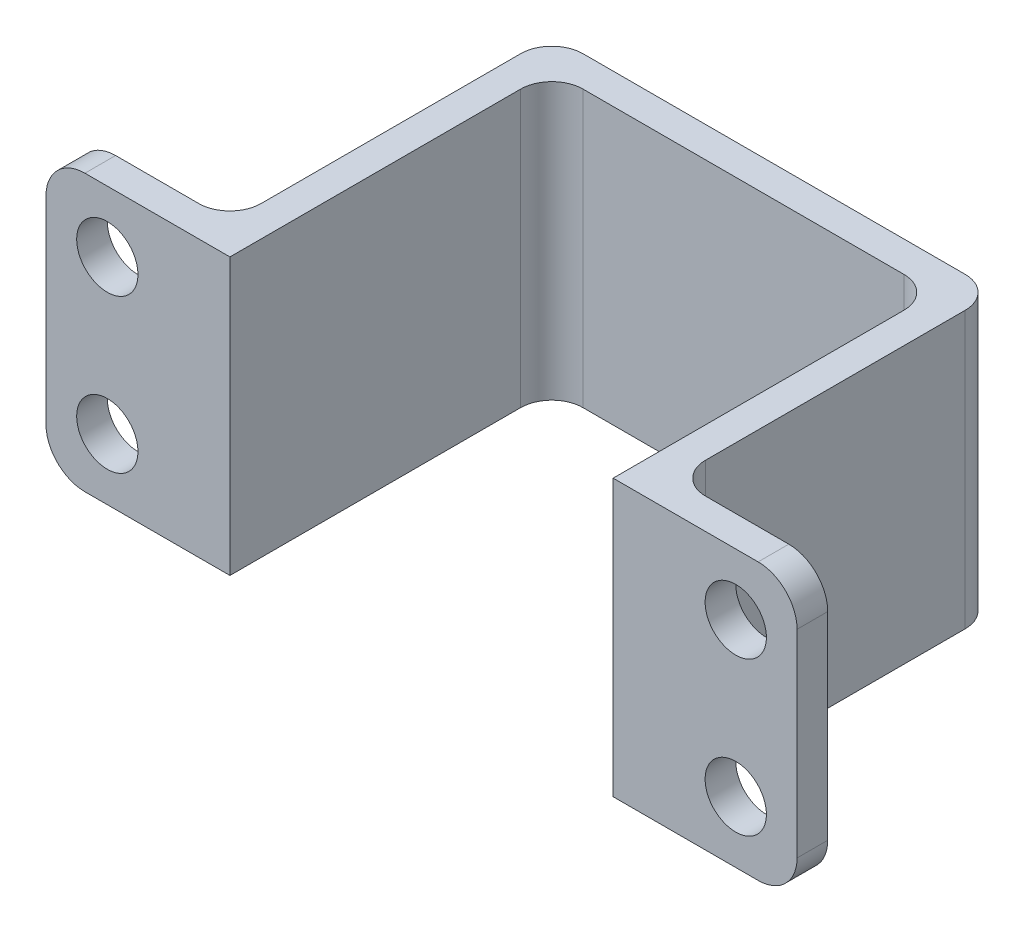
from build123d import *

# Parameters (mm, degrees)
BOSS_EXTRUDE1_DEPTH = 9
SKETCH2_R           = 1
CUT_EXTRUDE1_DEPTH  = 2
FILLET1_R           = 1.27


with BuildPart() as part:
    # Sketch1 → Boss-Extrude1 (new body)
    with BuildSketch(Plane(origin=(0, 0, 0), x_dir=(1, 0, 0), z_dir=(0, 1, 0))):
        with BuildLine():
            Line((12.5, 0), (13.5, 0))
            Line((13.5, 0), (18.5, 0))
            Line((18.5, 0), (18.5, 1))
            Line((18.5, 1), (14.516, 1))
            ThreePointArc((14.516, 1), (13.79757951, 1.29757951), (13.5, 2.016))
            Line((13.5, 2.016), (13.5, 10.484))
            ThreePointArc((13.5, 10.484), (13.20242049, 11.20242049), (12.484, 11.5))
            Line((12.484, 11.5), (0.016, 11.5))
            ThreePointArc((0.016, 11.5), (-0.70242049, 11.20242049), (-1, 10.484))
            Line((-1, 10.484), (-1, 2.016))
            ThreePointArc((-1, 2.016), (-1.29757951, 1.29757951), (-2.016, 1))
            Line((-2.016, 1), (-6, 1))
            Line((-6, 1), (-6, 0))
            Line((-6, 0), (-0.999998, 0))
            Line((-0.999998, 0), (0, 0))
            Line((0, 0), (0, 9.484))
            ThreePointArc((0, 9.484), (0.29757951, 10.20242049), (1.016, 10.5))
            Line((1.016, 10.5), (11.484, 10.5))
            ThreePointArc((11.484, 10.5), (12.20242049, 10.20242049), (12.5, 9.484))
            Line((12.5, 9.484), (12.5, 0))
        make_face()
    extrude(amount=BOSS_EXTRUDE1_DEPTH)

    # Sketch2 → Cut-Extrude1 (cut, through all)
    with BuildSketch(Plane(origin=(0, 0, -1), x_dir=(-1, 0, 0), z_dir=(0, 0, -1))):
        with Locations((4, 2)):
            Circle(SKETCH2_R)
        with Locations((4, 7)):
            Circle(SKETCH2_R)
        with Locations((-16.5, 2)):
            Circle(SKETCH2_R)
        with Locations((-16.5, 7)):
            Circle(SKETCH2_R)
    extrude(amount=-CUT_EXTRUDE1_DEPTH, mode=Mode.SUBTRACT)

    # Fillet1
    fillet1_edges = [part.edges().sort_by_distance(p)[0] for p in [
        (-6, 0, -0.5),
        (18.5, 0, -0.5),
        (18.5, 9, -0.5),
        (-6, 9, -0.5),
    ]]
    fillet(fillet1_edges, radius=FILLET1_R)


solid = part.part
